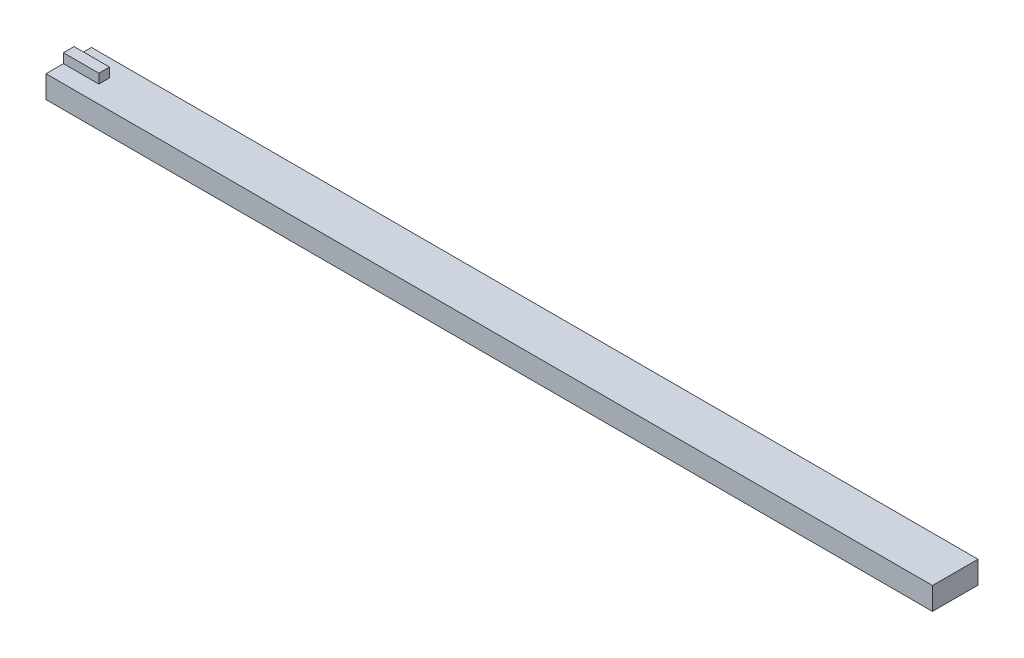
from build123d import *

# Parameters (mm, degrees)
SKETCH1_W           = 7.7
SKETCH1_H           = 3.8
BOSS_EXTRUDE1_DEPTH = 150
SKETCH2_W           = 6
SKETCH2_H           = 1.8
BOSS_EXTRUDE2_DEPTH = 1.6


with BuildPart() as part:
    # Sketch1 → Boss-Extrude1 (new body)
    with BuildSketch(Plane(origin=(0, 0, 0), x_dir=(0, 0, -1), z_dir=(1, 0, 0))):
        with Locations((3.85, 1.9)):
            Rectangle(SKETCH1_W, SKETCH1_H)
    extrude(amount=BOSS_EXTRUDE1_DEPTH)

    # Sketch2 → Boss-Extrude2 (add)
    with BuildSketch(Plane(origin=(0, 3.8, 0), x_dir=(1, 0, 0), z_dir=(0, 1, 0))):
        with Locations((3, 3.85)):
            Rectangle(SKETCH2_W, SKETCH2_H)
    extrude(amount=BOSS_EXTRUDE2_DEPTH)


solid = part.part
